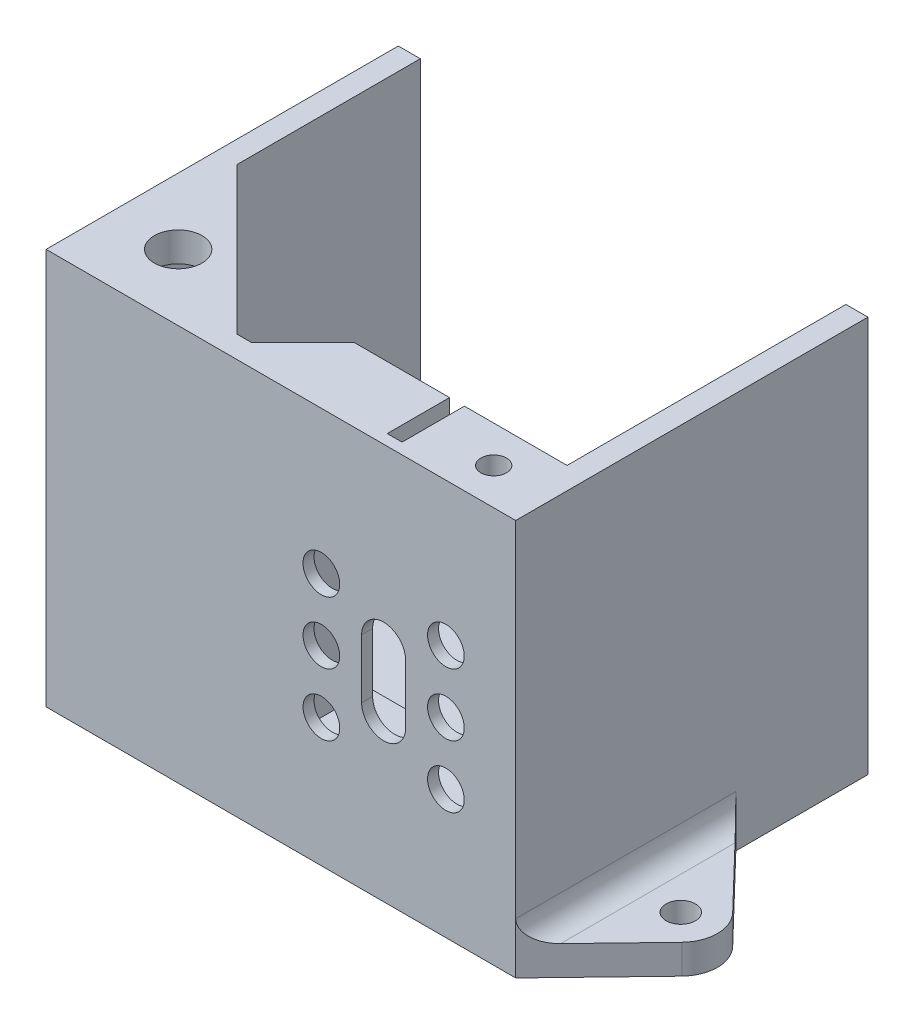
from build123d import *

# Parameters (mm, degrees)
SKETCH1_W            = 64
SKETCH1_H            = 48
BOSS_EXTRUDE1_DEPTH  = 4
CUT_EXTRUDE1_DEPTH   = 2.4
CUT_EXTRUDE2_DEPTH   = 2.4
BOSS_EXTRUDE3_DEPTH  = 50
BOSS_EXTRUDE4_DEPTH  = 50
SKETCH10_W           = 2.02372337
SKETCH10_H           = 15.25
SKETCH10_W_2         = 25.5
SKETCH10_H_2         = 25.5
CUT_EXTRUDE4_DEPTH   = 9.5
SKETCH13_W           = 36.946258726
SKETCH13_H           = 1
CUT_EXTRUDE6_DEPTH   = 32
SKETCH15_R           = 3.25
BOSS_EXTRUDE5_DEPTH  = 4
CUT_EXTRUDE7_DEPTH   = 7
SKETCH18_W           = 5.8
SKETCH18_H           = 2.6
CUT_EXTRUDE8_DEPTH   = 5
SKETCH19_R           = 1.75
BOSS_EXTRUDE8_DEPTH  = 4.4
FILLET1_R            = 1.5
SKETCH20_R           = 2
BOSS_EXTRUDE9_DEPTH  = 4
FILLET2_R            = 3
SKETCH22_R           = 1.75
CUT_EXTRUDE9_DEPTH   = 2
SKETCH23_R           = 2.5
CUT_EXTRUDE10_DEPTH  = 3
SKETCH24_W           = 2
SKETCH24_H           = 10
BOSS_EXTRUDE10_DEPTH = 4
SKETCH25_W           = 2
SKETCH25_H           = 10
BOSS_EXTRUDE11_DEPTH = 13
SKETCH26_W           = 2
SKETCH26_H           = 10
BOSS_EXTRUDE12_DEPTH = 4
FILLET4_R            = 1


with BuildPart() as part:
    # Sketch1 → Boss-Extrude1 (new body)
    with BuildSketch(Plane(origin=(0, 0, 0), x_dir=(1, 0, 0), z_dir=(0, 1, 0))):
        Rectangle(SKETCH1_W, SKETCH1_H)
    extrude(amount=BOSS_EXTRUDE1_DEPTH)

    # Sketch2 → Cut-Extrude1 (cut)
    with BuildSketch(Plane.XZ):
        Polygon((-20.651368439, -16), (-22.325684219, -13.1), (-25.674315781, -13.1), (-27.348631561, -16), (-25.674315781, -18.9), (-22.325684219, -18.9), align=None)
    extrude(amount=-CUT_EXTRUDE1_DEPTH, mode=Mode.SUBTRACT)

    # Sketch4 → Cut-Extrude2 (cut)
    with BuildSketch(Plane.XZ):
        Polygon((9.348631561, 10), (7.674315781, 12.9), (4.325684219, 12.9), (2.651368439, 10), (4.325684219, 7.1), (7.674315781, 7.1), align=None)
    extrude(amount=-CUT_EXTRUDE2_DEPTH, mode=Mode.SUBTRACT)

    # Sketch6 → Boss-Extrude3 (add)
    with BuildSketch(Plane(origin=(0, 4, 0), x_dir=(1, 0, 0), z_dir=(0, 1, 0))):
        Polygon((-29, -21), (-29, 21), (-29, 24), (-32, 24), (-32, -24), (32, -24), (32, 24), (29, 24), (29, 21), (29, -21), align=None)
    extrude(amount=BOSS_EXTRUDE3_DEPTH)

    # Sketch9 → Boss-Extrude4 (add)
    with BuildSketch(Plane(origin=(0, 4, 0), x_dir=(1, 0, 0), z_dir=(0, 1, 0))):
        Polygon((29, -13), (1, -13), (-7, -21), (29, -21), align=None)
    extrude(amount=BOSS_EXTRUDE4_DEPTH)

    # Sketch10 → Cut-Extrude4 (cut)
    with BuildSketch(Plane(origin=(0, 0, 13), x_dir=(-1, 0, 0), z_dir=(0, 0, -1))):
        with Locations((-14, 46.375)):
            Rectangle(SKETCH10_W, SKETCH10_H)
        with Locations((-14, 26)):
            Rectangle(SKETCH10_W_2, SKETCH10_H_2)
    extrude(amount=-CUT_EXTRUDE4_DEPTH, mode=Mode.SUBTRACT)

    # Sketch13 → Cut-Extrude6 (cut)
    with BuildSketch(Plane(origin=(0, 54, 0), x_dir=(1, 0, 0), z_dir=(0, 1, 0))):
        with Locations((10.526870637, -13.5)):
            Rectangle(SKETCH13_W, SKETCH13_H)
    extrude(amount=-CUT_EXTRUDE6_DEPTH, mode=Mode.SUBTRACT)

    # Sketch15 → Boss-Extrude5 (add)
    with BuildSketch(Plane(origin=(0, 54, 0), x_dir=(1, 0, 0), z_dir=(0, 1, 0))):
        Polygon((-29, -1), (-9, -21), (-29, -21), align=None)
        with Locations((-23, -15)):
            Circle(SKETCH15_R, mode=Mode.SUBTRACT)
    extrude(amount=-BOSS_EXTRUDE5_DEPTH)

    # Sketch17 → Cut-Extrude7 (cut)
    with BuildSketch(Plane(origin=(0, 54, 0), x_dir=(1, 0, 0), z_dir=(0, 1, 0))):
        Polygon((24, -15.651368439), (21.1, -17.325684219), (21.1, -20.674315781), (24, -22.348631561), (26.9, -20.674315781), (26.9, -17.325684219), align=None)
    extrude(amount=-CUT_EXTRUDE7_DEPTH, mode=Mode.SUBTRACT)

    # Sketch18 → Cut-Extrude8 (cut)
    with BuildSketch(Plane(origin=(0, 0, 14), x_dir=(-1, 0, 0), z_dir=(0, 0, -1))):
        with Locations((-24, 48.3)):
            Rectangle(SKETCH18_W, SKETCH18_H)
    extrude(amount=-CUT_EXTRUDE8_DEPTH, mode=Mode.SUBTRACT)

    # Sketch19 → Boss-Extrude8 (add)
    with BuildSketch(Plane(origin=(0, 54, 0), x_dir=(1, 0, 0), z_dir=(0, 1, 0))):
        Polygon((24, -15.651368439), (26.9, -17.325684219), (26.9, -20.674315781), (24, -22.348631561), (21.1, -20.674315781), (21.1, -17.325684219), align=None)
        with Locations((24, -19)):
            Circle(SKETCH19_R, mode=Mode.SUBTRACT)
    extrude(amount=-BOSS_EXTRUDE8_DEPTH)

    # Fillet1
    fillet1_edges = [part.edges().sort_by_distance(p)[0] for p in [
        (-29, 50, 11),
        (-19, 50, 21),
    ]]
    fillet(fillet1_edges, radius=FILLET1_R)

    # Sketch20 → Boss-Extrude9 (add)
    with BuildSketch(Plane.XZ):
        with BuildLine():
            Line((43.102082828, 12.467708073), (32.000000003, 23.999999995))
            Line((32.000000003, 23.999999995), (32, -6.000000006))
            Line((32, -6.000000006), (43.102082819, 5.532291906))
            ThreePointArc((43.102082819, 5.532291906), (44.500000003, 8.999999988), (43.102082828, 12.467708073))
        make_face()
        with Locations((39.500000002, 8.999999994)):
            Circle(SKETCH20_R, mode=Mode.SUBTRACT)
        with BuildLine():
            Line((-32, -24), (-32, 2.000000002))
            Line((-32, 2.000000002), (-42.978939192, -7.408763151))
            ThreePointArc((-42.978939192, -7.408763151), (-44.499999999, -10.999999999), (-42.978939192, -14.591236846))
            Line((-42.978939192, -14.591236846), (-32, -24))
        make_face()
        with Locations((-39.499999999, -10.999999999)):
            Circle(SKETCH20_R, mode=Mode.SUBTRACT)
    extrude(amount=-BOSS_EXTRUDE9_DEPTH)

    # Fillet2
    fillet2_edges = [part.edges().sort_by_distance(p)[0] for p in [
        (-32, 4, -10.999999999),
        (32.000000002, 4, 8.999999995),
    ]]
    fillet(fillet2_edges, radius=FILLET2_R)

    # Sketch22 → Cut-Extrude9 (cut)
    with BuildSketch(Plane.XZ.offset(-2.4)):
        with Locations((-24, -16)):
            Circle(SKETCH22_R)
        with Locations((6, 10)):
            Circle(SKETCH22_R)
    extrude(amount=-CUT_EXTRUDE9_DEPTH, mode=Mode.SUBTRACT)

    # Sketch23 → Cut-Extrude10 (cut)
    with BuildSketch(Plane(origin=(0, 0, 22.5), x_dir=(-1, 0, 0), z_dir=(0, 0, -1))):
        with Locations((-22.485281374, 34.485281374)):
            Circle(SKETCH23_R)
        with Locations((-5.514718626, 34.485281374)):
            Circle(SKETCH23_R)
        with Locations((-5.514718626, 17.514718626)):
            Circle(SKETCH23_R)
        with Locations((-22.485281374, 17.514718626)):
            Circle(SKETCH23_R)
        with Locations((-22.485281374, 26)):
            Circle(SKETCH23_R)
        with Locations((-5.514718626, 26)):
            Circle(SKETCH23_R)
        with BuildLine():
            Line((-11, 30), (-11, 22))
            ThreePointArc((-11, 22), (-14, 19), (-17, 22))
            Line((-17, 22), (-17, 30))
            ThreePointArc((-17, 30), (-14, 33), (-11, 30))
        make_face()
    extrude(amount=-CUT_EXTRUDE10_DEPTH, mode=Mode.SUBTRACT)

    # Sketch24 → Boss-Extrude10 (add)
    with BuildSketch(Plane.ZY.offset(-29)):
        with Locations((9, 27)):
            Rectangle(SKETCH24_W, SKETCH24_H)
    extrude(amount=BOSS_EXTRUDE10_DEPTH)

    # Sketch25 → Boss-Extrude11 (add)
    with BuildSketch(Plane(origin=(0, 0, 21), x_dir=(-1, 0, 0), z_dir=(0, 0, -1))):
        with Locations((2, 27)):
            Rectangle(SKETCH25_W, SKETCH25_H)
    extrude(amount=BOSS_EXTRUDE11_DEPTH)

    # Sketch26 → Boss-Extrude12 (add)
    with BuildSketch(Plane(origin=(-1, 0, 0), x_dir=(0, 0, -1), z_dir=(1, 0, 0))):
        with Locations((-9, 27)):
            Rectangle(SKETCH26_W, SKETCH26_H)
    extrude(amount=BOSS_EXTRUDE12_DEPTH)

    # Fillet4
    fillet4_edges = [part.edges().sort_by_distance(p)[0] for p in [
        (27, 32, 8),
        (27, 22, 8),
        (25, 32, 9),
        (25, 27, 8),
        (25, 22, 9),
        (-3, 22, 12.5),
        (-3, 32, 12.5),
        (-3, 27, 8),
        (0, 32, 8),
        (0, 22, 8),
        (3, 27, 8),
        (3, 32, 9),
        (3, 22, 9),
    ]]
    fillet(fillet4_edges, radius=FILLET4_R)


solid = part.part
